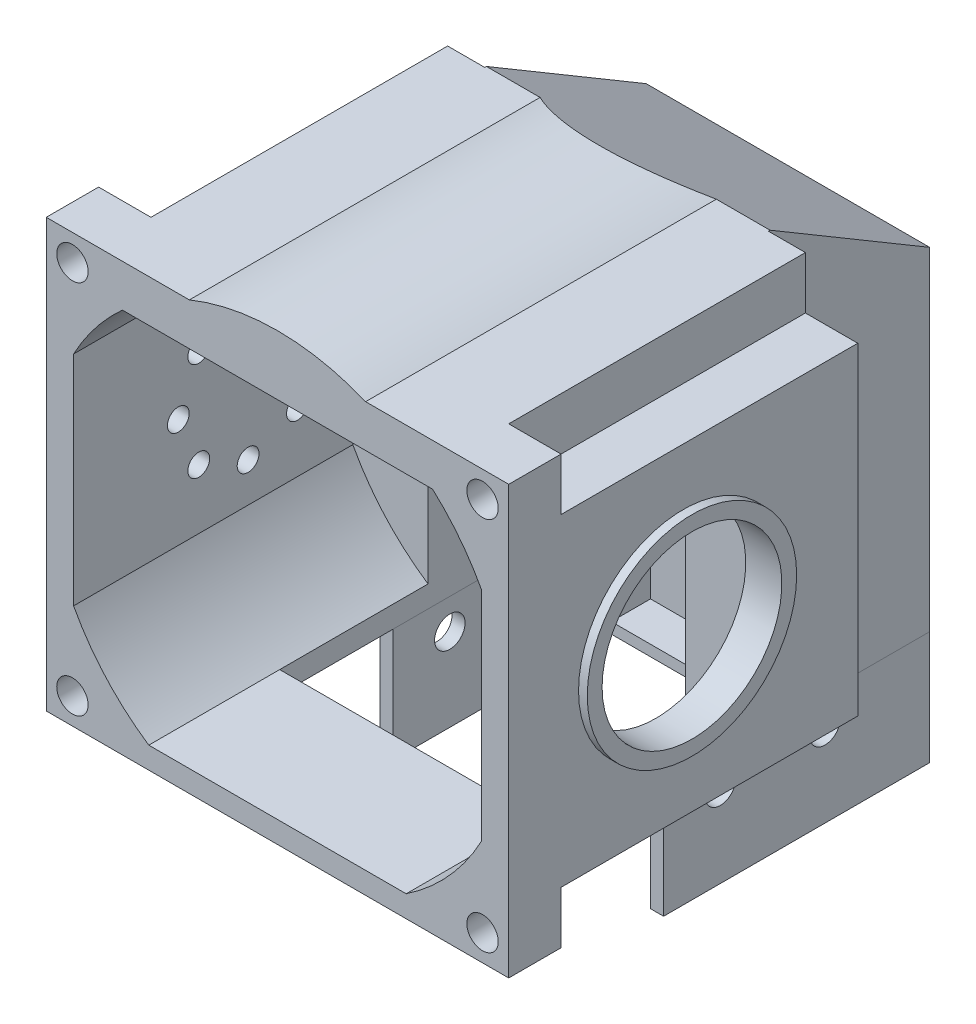
from build123d import *

# Parameters (mm, degrees)
SKETCH1_R                = 26.5
BOSS_EXTRUDE1_DEPTH      = 8
SKETCH2_W                = 3.133357109
SKETCH2_H                = 25
BOSS_EXTRUDE4_DEPTH      = 40
BOSS_EXTRUDE5_DEPTH      = 40
SKETCH4_W                = 32.5
SKETCH4_H                = 49
BOSS_EXTRUDE7_DEPTH      = 18.5
BOSS_EXTRUDE9_DEPTH      = 18.5
BOSS_EXTRUDE13_DEPTH     = 30.5
SKETCH8_R                = 2.637369172
CUT_EXTRUDE2_DEPTH       = 40
CUT_EXTRUDE2_DEPTH_BACK  = 25.5
SKETCH12_W               = 29.5
SKETCH12_H               = 2.484380545
BOSS_EXTRUDE14_DEPTH     = 15
SKETCH15_R               = 1.75
CUT_EXTRUDE3_DEPTH       = 40
SKETCH21_R               = 1.25
CUT_EXTRUDE10_DEPTH      = 7
BOSS_EXTRUDE16_DEPTH     = 32
SKETCH23_W               = 35
SKETCH23_H               = 6
CUT_EXTRUDE12_DEPTH      = 6
SKETCH24_W               = 35
SKETCH24_H               = 6
CUT_EXTRUDE13_DEPTH      = 6
SKETCH26_W               = 5
SKETCH26_H               = 15
CUT_EXTRUDE14_DEPTH      = 6
SKETCH27_R               = 1.8
CUT_EXTRUDE15_DEPTH      = 6
SKETCH18_R               = 10.3
CUT_EXTRUDE16_DEPTH      = 77.257786488
CUT_EXTRUDE16_DEPTH_BACK = 5
SKETCH28_W               = 29.5
SKETCH28_H               = 8.40335181
CUT_EXTRUDE17_DEPTH      = 15
SKETCH29_R               = 12
BOSS_EXTRUDE17_DEPTH     = 1
SKETCH30_R               = 10
CUT_EXTRUDE18_DEPTH      = 77.956156349
CUT_EXTRUDE18_DEPTH_BACK = 21
CUT_EXTRUDE19_DEPTH      = 70.525624772
SKETCH33_W               = 29.5
SKETCH33_H               = 1.25
CUT_EXTRUDE20_DEPTH      = 25
SKETCH34_R               = 10.3
CUT_EXTRUDE21_DEPTH      = 11


with BuildPart() as part:
    # Sketch1 → Boss-Extrude1 (new body)
    with BuildSketch(Plane.XY):
        Circle(SKETCH1_R)
    extrude(amount=BOSS_EXTRUDE1_DEPTH)

    # Sketch2 → Boss-Extrude4 (add)
    with BuildSketch(Plane(origin=(0, 0, 0), x_dir=(-1, 0, 0), z_dir=(0, 0, -1))):
        with BuildLine():
            ThreePointArc((26.5, 0), (25.704727548, 6.443367264), (23.366642891, 12.5))
            Line((23.366642891, 12.5), (23.366642891, -12.5))
            ThreePointArc((23.366642891, -12.5), (25.704727548, -6.443367264), (26.5, 0))
        make_face()
        with BuildLine():
            ThreePointArc((26.5, 0), (25.704727548, -6.443367264), (23.366642891, -12.5))
            Line((23.366642891, -12.5), (26.5, -12.5))
            Line((26.5, -12.5), (26.5, 0))
        make_face()
        with BuildLine():
            Line((26.5, 12.5), (23.366642891, 12.5))
            ThreePointArc((23.366642891, 12.5), (25.704727548, 6.443367264), (26.5, 0))
            Line((26.5, 0), (26.5, 12.5))
        make_face()
        with Locations((-24.933321445, 0)):
            Rectangle(SKETCH2_W, SKETCH2_H)
    extrude(amount=-BOSS_EXTRUDE4_DEPTH)

    # Sketch3 → Boss-Extrude5 (add)
    with BuildSketch(Plane(origin=(0, 0, 0), x_dir=(-1, 0, 0), z_dir=(0, 0, -1))):
        with BuildLine():
            Line((-26.5, 24.5), (-26.5, 12.5))
            Line((-26.5, 12.5), (-23.366642891, 12.5))
            ThreePointArc((-23.366642891, 12.5), (-17.776269649, 19.65335181), (-10.099504938, 24.5))
            Line((-10.099504938, 24.5), (-26.5, 24.5))
        make_face()
        with BuildLine():
            Line((-23.366642891, -12.5), (-26.5, -12.5))
            Line((-26.5, -12.5), (-26.5, -24.5))
            Line((-26.5, -24.5), (-10.099504938, -24.5))
            ThreePointArc((-10.099504938, -24.5), (-17.776269649, -19.65335181), (-23.366642891, -12.5))
        make_face()
        with BuildLine():
            Line((26.5, 24.5), (10.099504938, 24.5))
            ThreePointArc((10.099504938, 24.5), (17.776269649, 19.65335181), (23.366642891, 12.5))
            Line((23.366642891, 12.5), (26.5, 12.5))
            Line((26.5, 12.5), (26.5, 24.5))
        make_face()
        with BuildLine():
            ThreePointArc((23.366642891, -12.5), (17.776269649, -19.65335181), (10.099504938, -24.5))
            Line((10.099504938, -24.5), (26.5, -24.5))
            Line((26.5, -24.5), (26.5, -12.5))
            Line((26.5, -12.5), (23.366642891, -12.5))
        make_face()
    extrude(amount=-BOSS_EXTRUDE5_DEPTH)

    # Sketch4 → Boss-Extrude7 (add)
    with BuildSketch(Plane(origin=(0, 0, 0), x_dir=(-1, 0, 0), z_dir=(0, 0, -1))):
        Rectangle(SKETCH4_W, SKETCH4_H)
    extrude(amount=BOSS_EXTRUDE7_DEPTH)

    # Sketch7 → Boss-Extrude9 (add)
    with BuildSketch(Plane(origin=(0, 0, 0), x_dir=(-1, 0, 0), z_dir=(0, 0, -1))):
        with BuildLine():
            ThreePointArc((10.099504938, 24.5), (0, 26.5), (-10.099504938, 24.5))
            Line((-10.099504938, 24.5), (10.099504938, 24.5))
        make_face()
        with BuildLine():
            ThreePointArc((-10.099504938, -24.5), (0, -26.5), (10.099504938, -24.5))
            Line((10.099504938, -24.5), (-10.099504938, -24.5))
        make_face()
    extrude(amount=BOSS_EXTRUDE9_DEPTH)


with BuildPart() as body_2:
    # Sketch10 → Boss-Extrude13 (new body)
    with BuildSketch(Plane(origin=(0, 0, -18.5), x_dir=(-1, 0, 0), z_dir=(0, 0, -1))):
        with BuildLine():
            Line((16.25, -24.5), (16.25, -37.5))
            Line((16.25, -37.5), (-10.099504938, -37.5))
            Line((-10.099504938, -37.5), (-16.25, -37.5))
            Line((-16.25, -37.5), (-16.25, -24.5))
            Line((-16.25, -24.5), (-10.099504938, -24.5))
            ThreePointArc((-10.099504938, -24.5), (0, -26.5), (10.099504938, -24.5))
            Line((10.099504938, -24.5), (16.25, -24.5))
        make_face()
    extrude(amount=-BOSS_EXTRUDE13_DEPTH)


with BuildPart() as cut_extrude2_tool:
    # Sketch8 → Cut-Extrude2 (new, two sides)
    with BuildSketch(Plane.XY.offset(8)) as cut_extrude2_sk:
        with BuildLine():
            Line((-14.75, 11.25), (-14.75, -22.015619455))
            ThreePointArc((-14.75, -22.015619455), (-12.486693341, -23.373756425), (-10.099504938, -24.5))
            ThreePointArc((-10.099504938, -24.5), (0, -26.5), (10.099504938, -24.5))
            ThreePointArc((10.099504938, -24.5), (12.486693341, -23.373756425), (14.75, -22.015619455))
            Line((14.75, -22.015619455), (14.75, 11.25))
            Line((14.75, 11.25), (-14.75, 11.25))
        make_face()
        Circle(SKETCH8_R, mode=Mode.SUBTRACT)
        Circle(SKETCH8_R)
        with BuildLine():
            Line((-14.75, -22.015619455), (-14.75, -36.25))
            Line((-14.75, -36.25), (14.75, -36.25))
            Line((14.75, -36.25), (14.75, -22.015619455))
            ThreePointArc((14.75, -22.015619455), (12.486693341, -23.373756425), (10.099504938, -24.5))
            ThreePointArc((10.099504938, -24.5), (0, -26.5), (-10.099504938, -24.5))
            ThreePointArc((-10.099504938, -24.5), (-12.486693341, -23.373756425), (-14.75, -22.015619455))
        make_face()
    extrude(amount=CUT_EXTRUDE2_DEPTH)
    extrude(cut_extrude2_sk.sketch, amount=-CUT_EXTRUDE2_DEPTH_BACK)


with BuildPart() as part_1:
    add(part.part)

    # Cut-Extrude2: cut by cut_extrude2_tool
    add(cut_extrude2_tool.part, mode=Mode.SUBTRACT)

    # Sketch12 → Boss-Extrude14 (add)
    with BuildSketch(Plane.XY.offset(40)):
        with Locations((0, -23.257809728)):
            Rectangle(SKETCH12_W, SKETCH12_H)
    extrude(amount=-BOSS_EXTRUDE14_DEPTH)


with BuildPart() as body_2_1:
    add(body_2.part)

    # Cut-Extrude2: cut by cut_extrude2_tool
    add(cut_extrude2_tool.part, mode=Mode.SUBTRACT)


with BuildPart() as cut_extrude3_tool:
    # Sketch15 → Cut-Extrude3 (new body)
    with BuildSketch(Plane(origin=(16.25, 0, 0), x_dir=(0, 0, -1), z_dir=(1, 0, 0))):
        with Locations((6.5, -4)):
            Circle(SKETCH15_R)
        with Locations((-5.5, -4)):
            Circle(SKETCH15_R)
        with Locations((-5.5, -28)):
            Circle(SKETCH15_R)
        with Locations((6.5, -28)):
            Circle(SKETCH15_R)
    extrude(amount=-CUT_EXTRUDE3_DEPTH)


with BuildPart() as part_2:
    add(part_1.part)

    # Cut-Extrude3: cut by cut_extrude3_tool
    add(cut_extrude3_tool.part, mode=Mode.SUBTRACT)

    # Sketch21 → Cut-Extrude10 (cut)
    with BuildSketch(Plane.ZY.offset(26.5)):
        with Locations((25.656854249, -5.656854249)):
            Circle(SKETCH21_R)
        with Locations((20, 8)):
            Circle(SKETCH21_R)
        with Locations((20, -8)):
            Circle(SKETCH21_R)
        with Locations((14.343145751, -5.656854249)):
            Circle(SKETCH21_R)
        with Locations((12, 0)):
            Circle(SKETCH21_R)
        with Locations((14.343145751, 5.656854249)):
            Circle(SKETCH21_R)
        with Locations((25.656854249, 5.656854249)):
            Circle(SKETCH21_R)
        with Locations((28, 0)):
            Circle(SKETCH21_R)
    extrude(amount=-CUT_EXTRUDE10_DEPTH, mode=Mode.SUBTRACT)

    # Sketch22 → Boss-Extrude16 (add)
    with BuildSketch(Plane.XY.offset(8)):
        with BuildLine():
            Line((17.776269649, 19.65335181), (-17.776269649, 19.65335181))
            ThreePointArc((-17.776269649, 19.65335181), (0, 26.5), (17.776269649, 19.65335181))
        make_face()
    extrude(amount=BOSS_EXTRUDE16_DEPTH)

    # Sketch23 → Cut-Extrude12 (cut)
    with BuildSketch(Plane(origin=(26.5, 0, 0), x_dir=(0, 0, -1), z_dir=(1, 0, 0))):
        with Locations((-16.5, 21.5)):
            Rectangle(SKETCH23_W, SKETCH23_H)
        with Locations((-16.5, -21.5)):
            Rectangle(SKETCH23_W, SKETCH23_H)
    extrude(amount=-CUT_EXTRUDE12_DEPTH, mode=Mode.SUBTRACT)

    # Sketch24 → Cut-Extrude13 (cut)
    with BuildSketch(Plane.ZY.offset(26.5)):
        with Locations((16.5, -21.5)):
            Rectangle(SKETCH24_W, SKETCH24_H)
        with Locations((16.5, 21.5)):
            Rectangle(SKETCH24_W, SKETCH24_H)
    extrude(amount=-CUT_EXTRUDE13_DEPTH, mode=Mode.SUBTRACT)

    # Sketch26 → Cut-Extrude14 (cut)
    with BuildSketch(Plane.XY.offset(-17.5)):
        with Locations((12.25, -14.75)):
            Rectangle(SKETCH26_W, SKETCH26_H)
        with Locations((-12.25, -14.75)):
            Rectangle(SKETCH26_W, SKETCH26_H)
    extrude(amount=-CUT_EXTRUDE14_DEPTH, mode=Mode.SUBTRACT)

    # Sketch27 → Cut-Extrude15 (cut)
    with BuildSketch(Plane.XY.offset(40)):
        with Locations((-23.5, 21.5)):
            Circle(SKETCH27_R)
        with Locations((23.5, 21.5)):
            Circle(SKETCH27_R)
        with Locations(Location((23.5, -21.5, 0), (0, 0, 180))):
            Circle(SKETCH27_R)
        with Locations(Location((-23.5, -21.5, 0), (0, 0, 180))):
            Circle(SKETCH27_R)
    extrude(amount=-CUT_EXTRUDE15_DEPTH, mode=Mode.SUBTRACT)

    # Sketch18 → Cut-Extrude16 (cut, two sides)
    with BuildSketch(Plane(origin=(26.5, 0, 0), x_dir=(0, 0, -1), z_dir=(1, 0, 0))) as cut_extrude16_sk:
        with Locations(Location((-20, 0, 0), (0, 0, 180))):
            Circle(SKETCH18_R)
    extrude(amount=CUT_EXTRUDE16_DEPTH, mode=Mode.SUBTRACT)
    extrude(cut_extrude16_sk.sketch, amount=-CUT_EXTRUDE16_DEPTH_BACK, mode=Mode.SUBTRACT)

    # Sketch28 → Cut-Extrude17 (cut)
    with BuildSketch(Plane.XY.offset(8)):
        with Locations((0, 15.451675905)):
            Rectangle(SKETCH28_W, SKETCH28_H)
    extrude(amount=-CUT_EXTRUDE17_DEPTH, mode=Mode.SUBTRACT)

    # Sketch29 → Boss-Extrude17 (add)
    with BuildSketch(Plane(origin=(26.5, 0, 0), x_dir=(0, 0, -1), z_dir=(1, 0, 0))):
        with Locations((-20, 0)):
            Circle(SKETCH29_R)
    extrude(amount=BOSS_EXTRUDE17_DEPTH)

    # Sketch30 → Cut-Extrude18 (cut, two sides)
    with BuildSketch(Plane(origin=(27.5, 0, 0), x_dir=(0, 0, -1), z_dir=(1, 0, 0))) as cut_extrude18_sk:
        with Locations(Location((-20, 0, 0), (0, 0, 180))):
            Circle(SKETCH30_R)
    extrude(amount=CUT_EXTRUDE18_DEPTH, mode=Mode.SUBTRACT)
    extrude(cut_extrude18_sk.sketch, amount=-CUT_EXTRUDE18_DEPTH_BACK, mode=Mode.SUBTRACT)

    # Sketch32 → Cut-Extrude19 (cut, through all)
    with BuildSketch(Plane(origin=(16.25, 0, 0), x_dir=(0, 0, -1), z_dir=(1, 0, 0))):
        Polygon((18.5, 13.640685203), (-3.179032594, 26.5), (18.5, 26.5), align=None)
    extrude(amount=-CUT_EXTRUDE19_DEPTH, mode=Mode.SUBTRACT)

    # Sketch34 → Cut-Extrude21 (cut)
    with BuildSketch(Plane(origin=(27.5, 0, 0), x_dir=(0, 0, -1), z_dir=(1, 0, 0))):
        with Locations(Location((-20, 0, 0), (0, 0, 180))):
            Circle(SKETCH34_R)
    extrude(amount=-CUT_EXTRUDE21_DEPTH, mode=Mode.SUBTRACT)


with BuildPart() as body_2_2:
    add(body_2_1.part)

    # Cut-Extrude3: cut by cut_extrude3_tool
    add(cut_extrude3_tool.part, mode=Mode.SUBTRACT)

    # Sketch33 → Cut-Extrude20 (cut)
    with BuildSketch(Plane.XY.offset(12)):
        with Locations((0, -36.875)):
            Rectangle(SKETCH33_W, SKETCH33_H)
    extrude(amount=-CUT_EXTRUDE20_DEPTH, mode=Mode.SUBTRACT)


solid = Compound([part_2.part, body_2_2.part])
